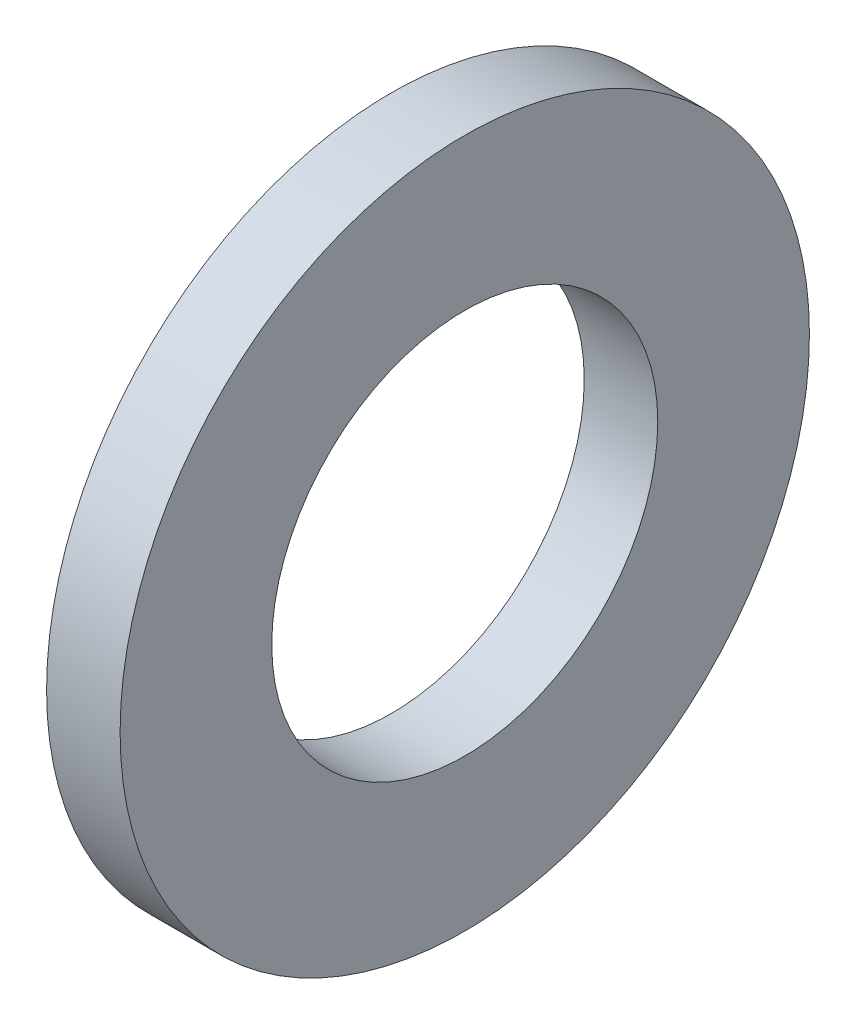
from build123d import *

# Parameters (mm, degrees)
SKETCH1_W = 1.6
SKETCH1_H = 3.3


with BuildPart() as part:
    # Sketch1 → Base-Revolve (revolve)
    with BuildSketch(Plane.XY):
        with Locations((-0.8, 5.85)):
            Rectangle(SKETCH1_W, SKETCH1_H)
    revolve(axis=Axis((-34.925, 0, 0), (1, 0, 0)))


solid = part.part
